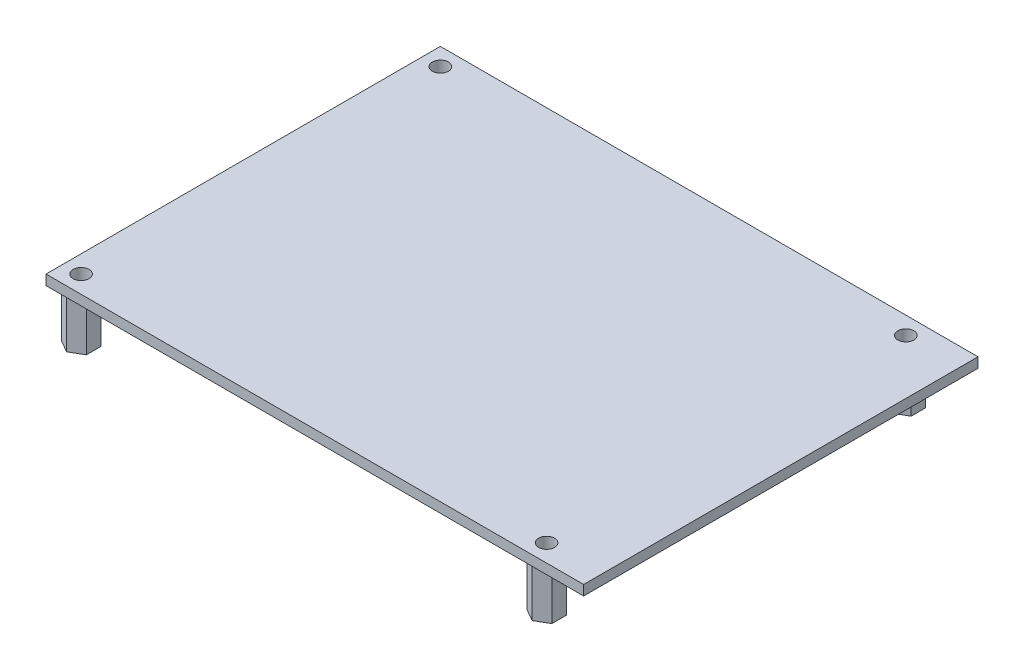
from build123d import *

# Parameters (mm, degrees)
SKETCH_1_W          = 107.3
SKETCH_1_H          = 78.7
SKETCH_1_R          = 1.6
EXTRUDE_1_DEPTH     = 2
EXTRUDE_2_DEPTH     = 10
SKETCH_3_R          = 1.6
CUT_EXTRUDE_1_DEPTH = 11


with BuildPart() as part:
    # Эскиз1 → Бобышка-Вытянуть1 (new body)
    with BuildSketch(Plane(origin=(0, 0, 0), x_dir=(1, 0, 0), z_dir=(0, 1, 0))):
        with Locations((53.65, 39.35)):
            Rectangle(SKETCH_1_W, SKETCH_1_H)
        with Locations((3.5, 75.2)):
            Circle(SKETCH_1_R, mode=Mode.SUBTRACT)
        with Locations((96.4, 75.2)):
            Circle(SKETCH_1_R, mode=Mode.SUBTRACT)
        with Locations((96.4, 3.5)):
            Circle(SKETCH_1_R, mode=Mode.SUBTRACT)
        with Locations((3.5, 3.5)):
            Circle(SKETCH_1_R, mode=Mode.SUBTRACT)
    extrude(amount=EXTRUDE_1_DEPTH)

    # Эскиз2 → Бобышка-Вытянуть2 (add)
    with BuildSketch(Plane.XZ):
        Polygon((93.9, -4.943375673), (96.4, -6.386751346), (98.9, -4.943375673), (98.9, -2.056624327), (96.4, -0.613248654), (93.9, -2.056624327), align=None)
        Polygon((93.9, -76.643375673), (96.4, -78.086751346), (98.9, -76.643375673), (98.9, -73.756624327), (96.4, -72.313248654), (93.9, -73.756624327), align=None)
        Polygon((3.5, -6.386751346), (6, -4.943375673), (6, -2.056624327), (3.5, -0.613248654), (1, -2.056624327), (1, -4.943375673), align=None)
        Polygon((3.5, -72.313248654), (1, -73.756624327), (1, -76.643375673), (3.5, -78.086751346), (6, -76.643375673), (6, -73.756624327), align=None)
    extrude(amount=EXTRUDE_2_DEPTH)

    # Эскиз3 → Вырез-Вытянуть1 (cut, through all)
    with BuildSketch(Plane(origin=(0, 0, 0), x_dir=(1, 0, 0), z_dir=(0, 1, 0))):
        with Locations((3.5, 3.5)):
            Circle(SKETCH_3_R)
        with Locations((3.5, 75.2)):
            Circle(SKETCH_3_R)
        with Locations((96.4, 75.2)):
            Circle(SKETCH_3_R)
        with Locations((96.4, 3.5)):
            Circle(SKETCH_3_R)
    extrude(amount=-CUT_EXTRUDE_1_DEPTH, mode=Mode.SUBTRACT)


solid = part.part
